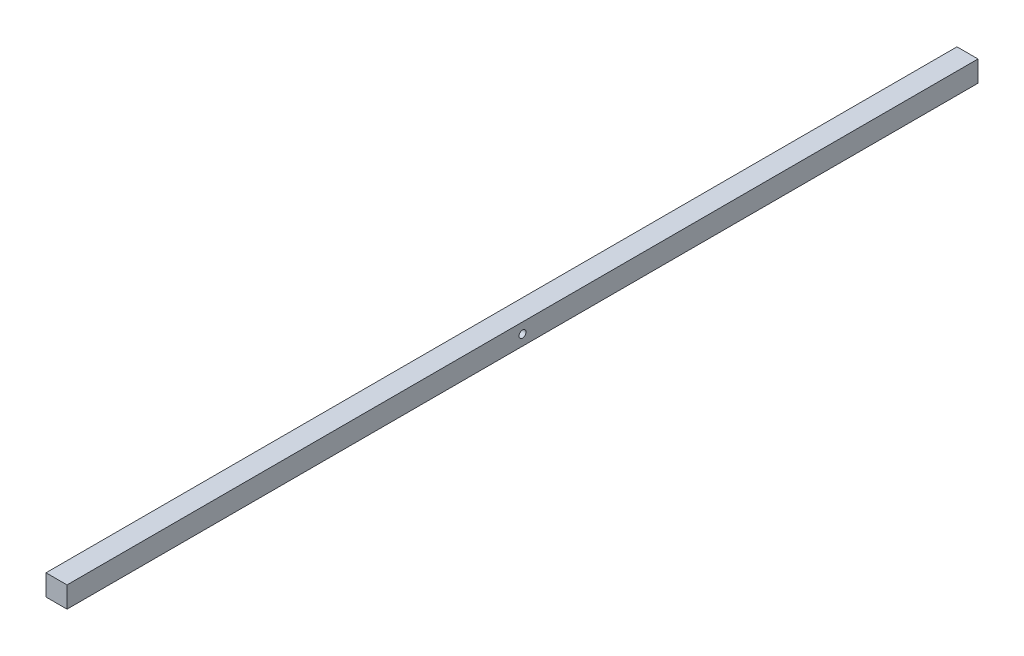
from build123d import *

# Parameters (mm, degrees)
ESBO_O1_W                = 6
ESBO_O1_H                = 6
RESSALTO_EXTRUS_O1_DEPTH = 260
ESBO_O2_R                = 1
CORTE_EXTRUS_O1_DEPTH    = 10


with BuildPart() as part:
    # Esboço1 → Ressalto-extrusão1 (new body)
    with BuildSketch(Plane.XY):
        Rectangle(ESBO_O1_W, ESBO_O1_H)
    extrude(amount=RESSALTO_EXTRUS_O1_DEPTH)

    # Esboço2 → Corte-extrusão1 (cut)
    with BuildSketch(Plane.ZY.offset(3)):
        with Locations((130, 0)):
            Circle(ESBO_O2_R)
    extrude(amount=-CORTE_EXTRUS_O1_DEPTH, mode=Mode.SUBTRACT)


solid = part.part
